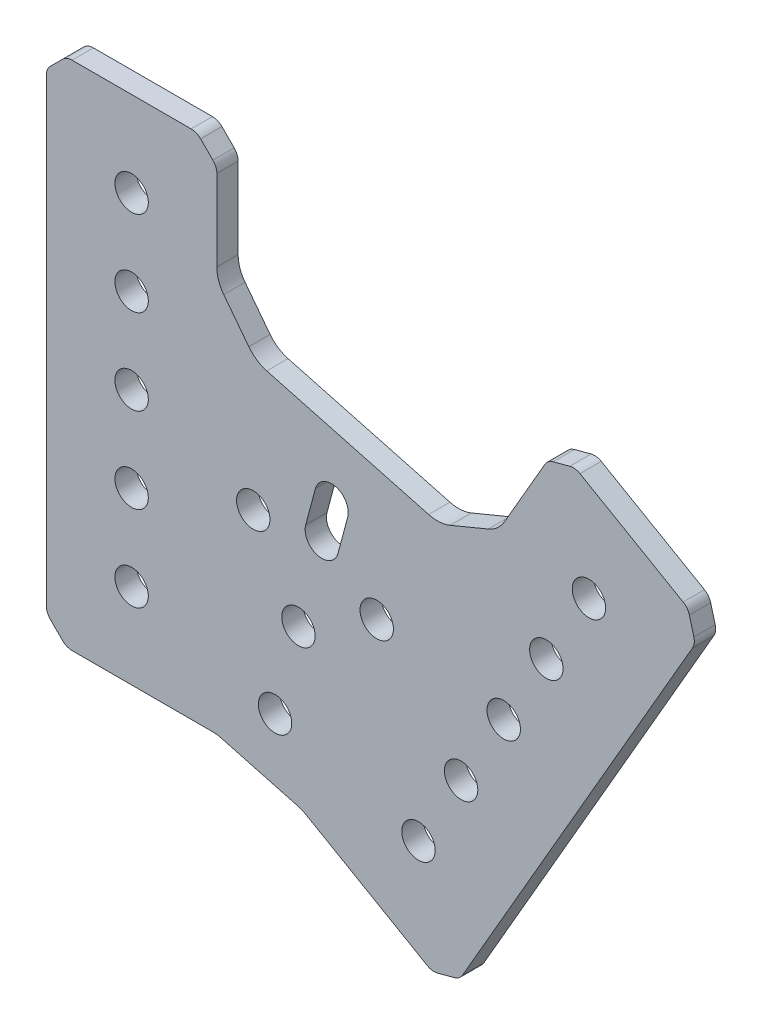
from build123d import *

# Parameters (mm, degrees)
SKETCH1_R           = 2.4892
BOSS_EXTRUDE1_DEPTH = 3.175


with BuildPart() as part:
    # Sketch1 → Boss-Extrude1 (new body)
    with BuildSketch(Plane(origin=(0, 0, 0), x_dir=(-1, 0, 0), z_dir=(0, 0, -1))):
        with BuildLine():
            Line((-2.414213562, 0.585786438), (-0.585786438, 2.414213562))
            ThreePointArc((-0.585786438, 2.414213562), (-0.152240935, 3.06306026), (0, 3.828427125))
            Line((0, 3.828427125), (0, 72.371572875))
            ThreePointArc((0, 72.371572875), (-0.152240935, 73.13693974), (-0.585786438, 73.785786438))
            Line((-0.585786438, 73.785786438), (-2.414213562, 75.614213562))
            ThreePointArc((-2.414213562, 75.614213562), (-3.06306026, 76.047759065), (-3.828427125, 76.2))
            Line((-3.828427125, 76.2), (-21.571572875, 76.2))
            ThreePointArc((-21.571572875, 76.2), (-22.33693974, 76.047759065), (-22.985786438, 75.614213562))
            Line((-22.985786438, 75.614213562), (-24.814213562, 73.785786438))
            ThreePointArc((-24.814213562, 73.785786438), (-25.247759065, 73.13693974), (-25.4, 72.371572875))
            Line((-25.4, 72.371572875), (-25.4, 60.289301259))
            ThreePointArc((-25.4, 60.289301259), (-25.665349353, 58.682103933), (-26.433233299, 57.245494114))
            Line((-26.433233299, 57.245494114), (-30.162321659, 52.385651545))
            ThreePointArc((-30.162321659, 52.385651545), (-31.351237196, 51.272110628), (-32.834993135, 50.599829559))
            Line((-32.834993135, 50.599829559), (-56.961021847, 44.135279649))
            ThreePointArc((-56.961021847, 44.135279649), (-58.582132719, 43.975614164), (-60.168534235, 44.345511117))
            Line((-60.168534235, 44.345511117), (-65.827940772, 46.68971406))
            ThreePointArc((-65.827940772, 46.68971406), (-67.211252686, 47.549912686), (-68.24465063, 48.809111723))
            Line((-68.24465063, 48.809111723), (-74.285786438, 59.272665878))
            ThreePointArc((-74.285786438, 59.272665878), (-74.800314387, 59.859372559), (-75.500199155, 60.204517531))
            Line((-75.500199155, 60.204517531), (-77.997877056, 60.873768307))
            ThreePointArc((-77.997877056, 60.873768307), (-78.776567531, 60.924806377), (-79.515515147, 60.673967462))
            Line((-79.515515147, 60.673967462), (-94.88153011, 51.802394587))
            ThreePointArc((-94.88153011, 51.802394587), (-95.46823679, 51.287866637), (-95.813381762, 50.58798187))
            Line((-95.813381762, 50.58798187), (-96.482632539, 48.090303968))
            ThreePointArc((-96.482632539, 48.090303968), (-96.533670609, 47.311613493), (-96.282831694, 46.572665878))
            Line((-96.282831694, 46.572665878), (-62.011258818, -12.787439597))
            ThreePointArc((-62.011258818, -12.787439597), (-61.496730869, -13.374146278), (-60.796846101, -13.71929125))
            Line((-60.796846101, -13.71929125), (-58.2991682, -14.388542027))
            ThreePointArc((-58.2991682, -14.388542027), (-57.520477725, -14.439580097), (-56.78153011, -14.188741182))
            Line((-56.78153011, -14.188741182), (-38.670072037, -3.732085988))
            ThreePointArc((-38.670072037, -3.732085988), (-38.083489199, -3.442815344), (-37.464167262, -3.232583875))
            Line((-37.464167262, -3.232583875), (-26.035832738, -0.170370869))
            ThreePointArc((-26.035832738, -0.170370869), (-25.394368473, -0.042775693), (-24.741737512, 0))
            Line((-24.741737512, 0), (-3.828427125, 0))
            ThreePointArc((-3.828427125, 0), (-3.06306026, 0.152240935), (-2.414213562, 0.585786438))
        make_face()
        with Locations((-12.7, 12.7)):
            Circle(SKETCH1_R, mode=Mode.SUBTRACT)
        with Locations((-61.798522628, 12.244090512)):
            Circle(SKETCH1_R, mode=Mode.SUBTRACT)
        with Locations((-74.498522628, 34.241135768)):
            Circle(SKETCH1_R, mode=Mode.SUBTRACT)
        with Locations((-12.7, 25.4)):
            Circle(SKETCH1_R, mode=Mode.SUBTRACT)
        with Locations((-80.848522628, 45.239658396)):
            Circle(SKETCH1_R, mode=Mode.SUBTRACT)
        with Locations((-68.148522628, 23.24261314)):
            Circle(SKETCH1_R, mode=Mode.SUBTRACT)
        with Locations((-55.448522628, 1.245567884)):
            Circle(SKETCH1_R, mode=Mode.SUBTRACT)
        with Locations((-12.7, 38.1)):
            Circle(SKETCH1_R, mode=Mode.SUBTRACT)
        with Locations((-30.825461194, 31.649870813)):
            Circle(SKETCH1_R, mode=Mode.SUBTRACT)
        with Locations((-12.7, 50.8)):
            Circle(SKETCH1_R, mode=Mode.SUBTRACT)
        with Locations((-12.7, 63.5)):
            Circle(SKETCH1_R, mode=Mode.SUBTRACT)
        with Locations((-49.226348185, 26.719368004)):
            Circle(SKETCH1_R, mode=Mode.SUBTRACT)
        with Locations((-37.560653285, 19.984175913)):
            Circle(SKETCH1_R, mode=Mode.SUBTRACT)
        with Locations((-34.074261314, 6.972783942)):
            Circle(SKETCH1_R, mode=Mode.SUBTRACT)
        with BuildLine():
            Line((-43.451427823, 32.351315517), (-44.895538661, 37.740810537))
            ThreePointArc((-44.895538661, 37.740810537), (-43.135408461, 40.789445471), (-40.086773527, 39.029315271))
            Line((-40.086773527, 39.029315271), (-38.642662689, 33.639820251))
            ThreePointArc((-38.642662689, 33.639820251), (-40.402792889, 30.591185317), (-43.451427823, 32.351315517))
        make_face(mode=Mode.SUBTRACT)
    extrude(amount=-BOSS_EXTRUDE1_DEPTH)


solid = part.part
